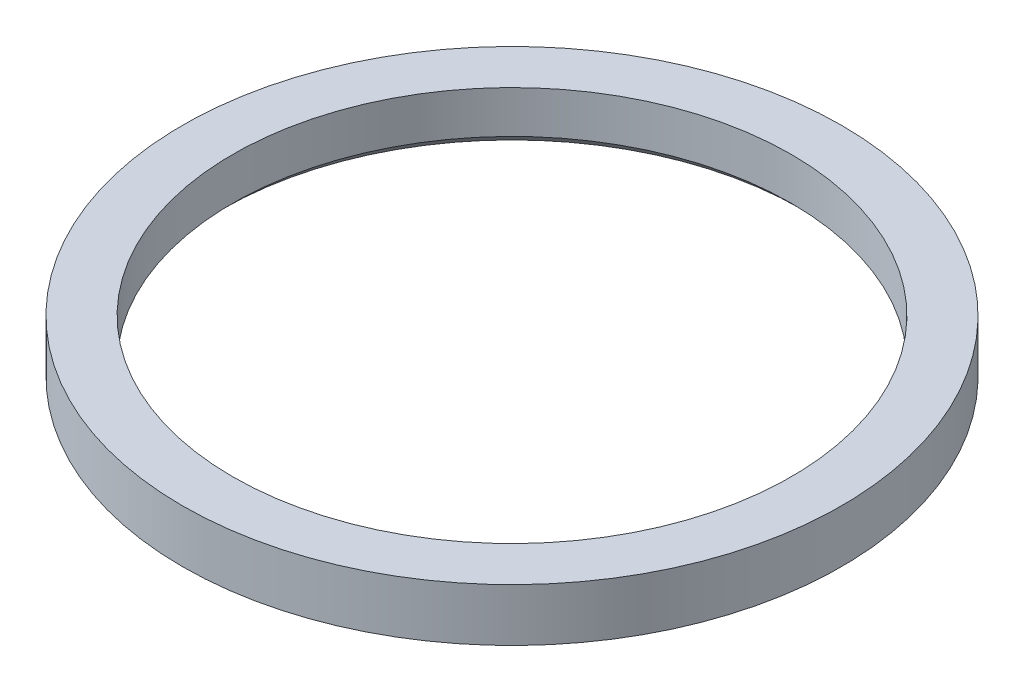
from build123d import *

# Parameters (mm, degrees)
SKETCH1_R           = 9.5
BOSS_EXTRUDE1_DEPTH = 1.52
SKETCH2_R           = 8.05
CUT_EXTRUDE1_DEPTH  = 2.52
CHAMFER1_SIZE       = 0.3


with BuildPart() as part:
    # Sketch1 → Boss-Extrude1 (new body)
    with BuildSketch(Plane(origin=(0, 0, 0), x_dir=(1, 0, 0), z_dir=(0, 1, 0))):
        Circle(SKETCH1_R)
    extrude(amount=BOSS_EXTRUDE1_DEPTH)

    # Sketch2 → Cut-Extrude1 (cut, through all)
    with BuildSketch(Plane(origin=(0, 1.52, 0), x_dir=(1, 0, 0), z_dir=(0, 1, 0))):
        Circle(SKETCH2_R)
    extrude(amount=-CUT_EXTRUDE1_DEPTH, mode=Mode.SUBTRACT)

    # Chamfer1
    chamfer1_edges = [part.edges().sort_by_distance(p)[0] for p in [
        (-8.05, 0, 0),
    ]]
    chamfer(chamfer1_edges, length=CHAMFER1_SIZE)


solid = part.part
